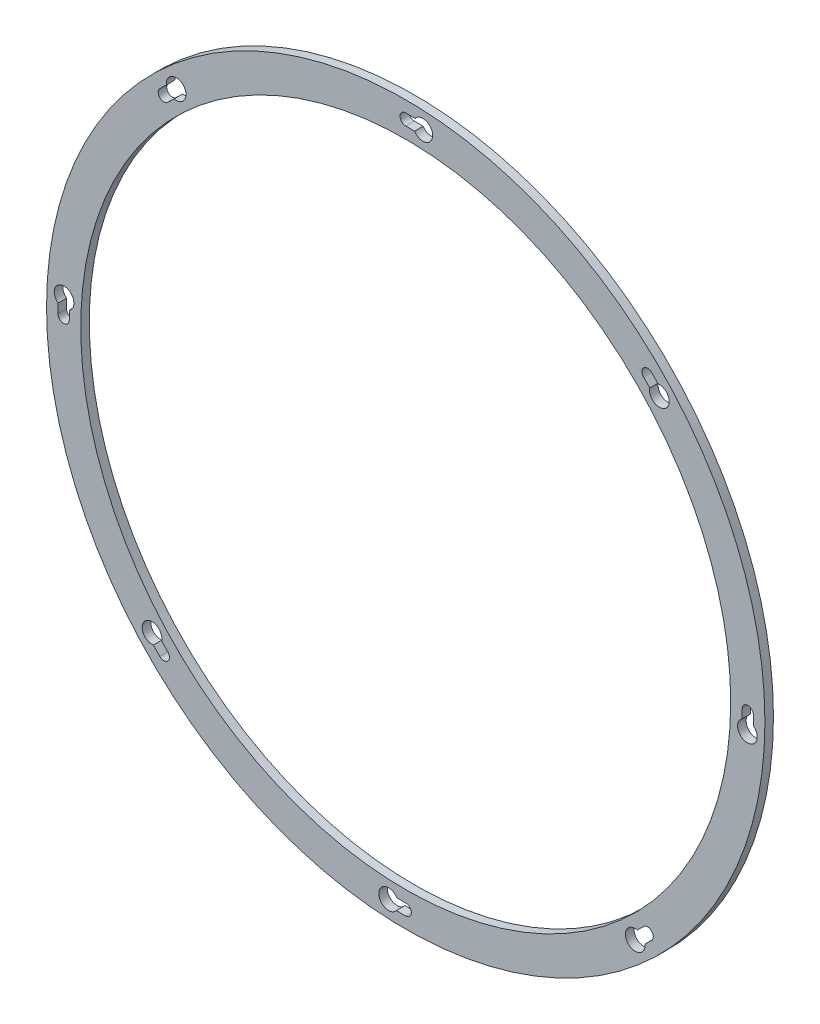
from build123d import *

# Parameters (mm, degrees)
SKETCH1_R            = 210
SKETCH1_R_2          = 190
BOSS_EXTRUDE1_DEPTH  = 5
M6_CLEARANCE_HOLE1_D = 6.6
CUT_EXTRUDE1_DEPTH   = 5
CIRPATTERN1_COUNT    = 8


with BuildPart() as part:
    # Sketch1 → Boss-Extrude1 (new body)
    with BuildSketch(Plane.XY):
        Circle(SKETCH1_R)
        Circle(SKETCH1_R_2, mode=Mode.SUBTRACT)
    extrude(amount=BOSS_EXTRUDE1_DEPTH)

    # M6 Clearance Hole1 (through all)
    with Locations(Plane.XY.offset(5)):
        with Locations((0, 200)):
            m6_clearance_hole1 = Hole(M6_CLEARANCE_HOLE1_D / 2)

    # Sketch4 → Cut-Extrude1 (cut)
    with BuildSketch(Plane.XY.offset(5)):
        with BuildLine():
            ThreePointArc((5.165561681, 196.632161592), (15.742672541, 199.530216011), (5.41785296, 203.227795514))
            ThreePointArc((5.41785296, 203.227795514), (2.709167039, 203.281948077), (0, 203.3))
            ThreePointArc((0, 203.3), (3.3, 200), (0, 196.7))
            ThreePointArc((0, 196.7), (2.583003558, 196.683039667), (5.165561681, 196.632161592))
        make_face()
    cut_extrude1 = extrude(amount=-CUT_EXTRUDE1_DEPTH, mode=Mode.SUBTRACT)

    # CirPattern1: M6 Clearance Hole1, Cut-Extrude1 ×8 about axis
    cirpattern1_axis = Axis((0, 0, 0), (0, 0, 1))
    for i in range(1, CIRPATTERN1_COUNT):
        add(m6_clearance_hole1.rotate(cirpattern1_axis, i * 360 / CIRPATTERN1_COUNT), mode=Mode.SUBTRACT)
        add(cut_extrude1.rotate(cirpattern1_axis, i * 360 / CIRPATTERN1_COUNT), mode=Mode.SUBTRACT)


solid = part.part
